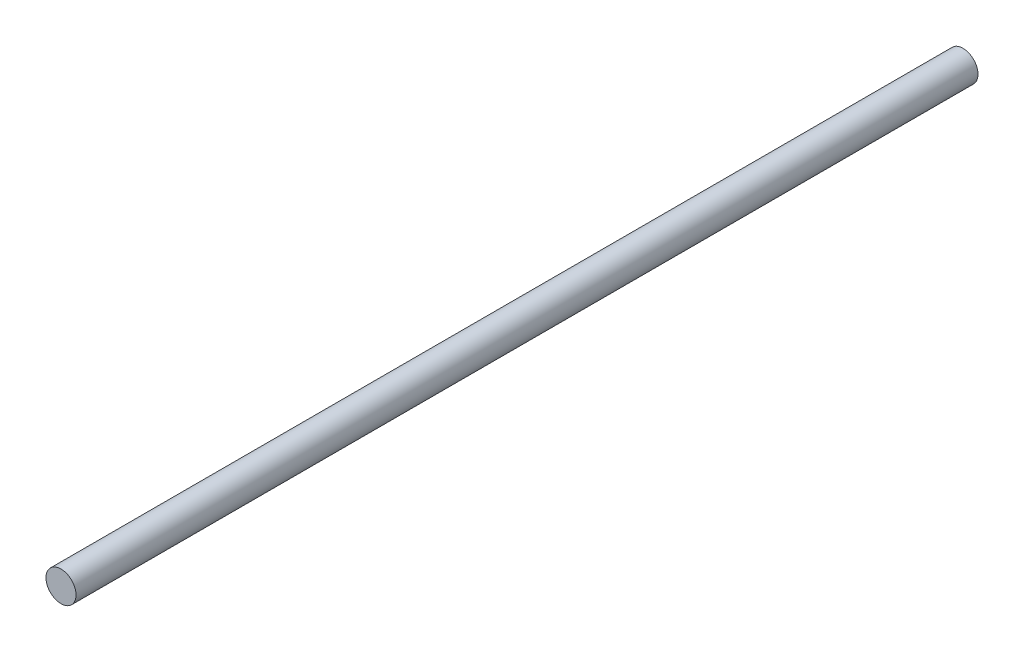
from build123d import *

# Parameters (mm, degrees)
SKETCH1_R           = 1.5
BOSS_EXTRUDE1_DEPTH = 90


with BuildPart() as part:
    # Sketch1 → Boss-Extrude1 (new body)
    with BuildSketch(Plane.XY):
        Circle(SKETCH1_R)
    extrude(amount=BOSS_EXTRUDE1_DEPTH)


solid = part.part
